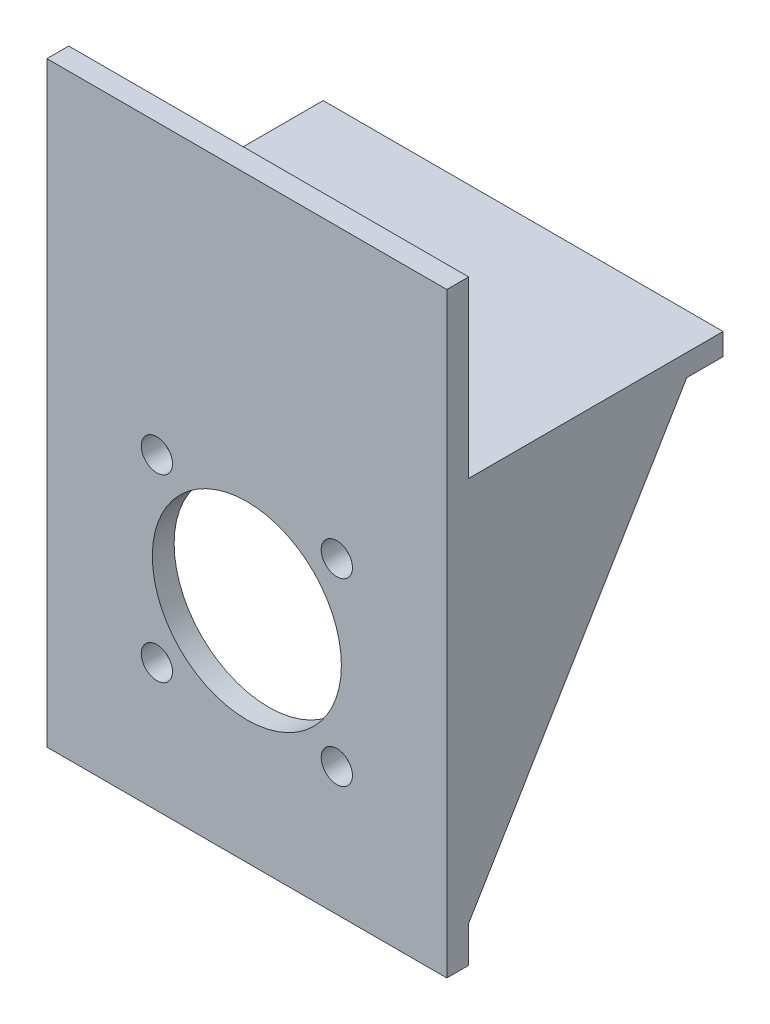
from build123d import *

# Parameters (mm, degrees)
SKETCH1_W           = 55
SKETCH1_H           = 35
BOSS_EXTRUDE1_DEPTH = 3
SKETCH2_W           = 55
SKETCH2_H           = 82
BOSS_EXTRUDE2_DEPTH = 3
BOSS_EXTRUDE3_DEPTH = 3
BOSS_EXTRUDE4_DEPTH = 3
SKETCH5_R           = 13
SKETCH5_R_2         = 2.15
CUT_EXTRUDE1_DEPTH  = 3


with BuildPart() as part:
    # Sketch1 → Boss-Extrude1 (new body)
    with BuildSketch(Plane(origin=(0, 0, 0), x_dir=(1, 0, 0), z_dir=(0, 1, 0))):
        Rectangle(SKETCH1_W, SKETCH1_H)
    extrude(amount=BOSS_EXTRUDE1_DEPTH)

    # Sketch2 → Boss-Extrude2 (add)
    with BuildSketch(Plane.XY.offset(17.5)):
        with Locations((0, -14)):
            Rectangle(SKETCH2_W, SKETCH2_H)
    extrude(amount=BOSS_EXTRUDE2_DEPTH)

    # Sketch3 → Boss-Extrude3 (add)
    with BuildSketch(Plane(origin=(27.5, 0, 0), x_dir=(0, 0, -1), z_dir=(1, 0, 0))):
        Polygon((-17.5, 0), (12.5, 0), (-17.5, -50), align=None)
    extrude(amount=-BOSS_EXTRUDE3_DEPTH)

    # Sketch4 → Boss-Extrude4 (add)
    with BuildSketch(Plane.ZY.offset(27.5)):
        Polygon((-12.5, 0), (17.5, 0), (17.5, -50), align=None)
    extrude(amount=-BOSS_EXTRUDE4_DEPTH)

    # Sketch5 → Cut-Extrude1 (cut)
    with BuildSketch(Plane(origin=(0, 0, 17.5), x_dir=(-1, 0, 0), z_dir=(0, 0, -1))):
        with Locations((0, -25)):
            Circle(SKETCH5_R)
        with Locations((12.374368671, -12.625631329)):
            Circle(SKETCH5_R_2)
        with Locations((12.374368671, -37.374368671)):
            Circle(SKETCH5_R_2)
        with Locations((-12.374368671, -37.374368671)):
            Circle(SKETCH5_R_2)
        with Locations((-12.374368671, -12.625631329)):
            Circle(SKETCH5_R_2)
    extrude(amount=-CUT_EXTRUDE1_DEPTH, mode=Mode.SUBTRACT)


solid = part.part
